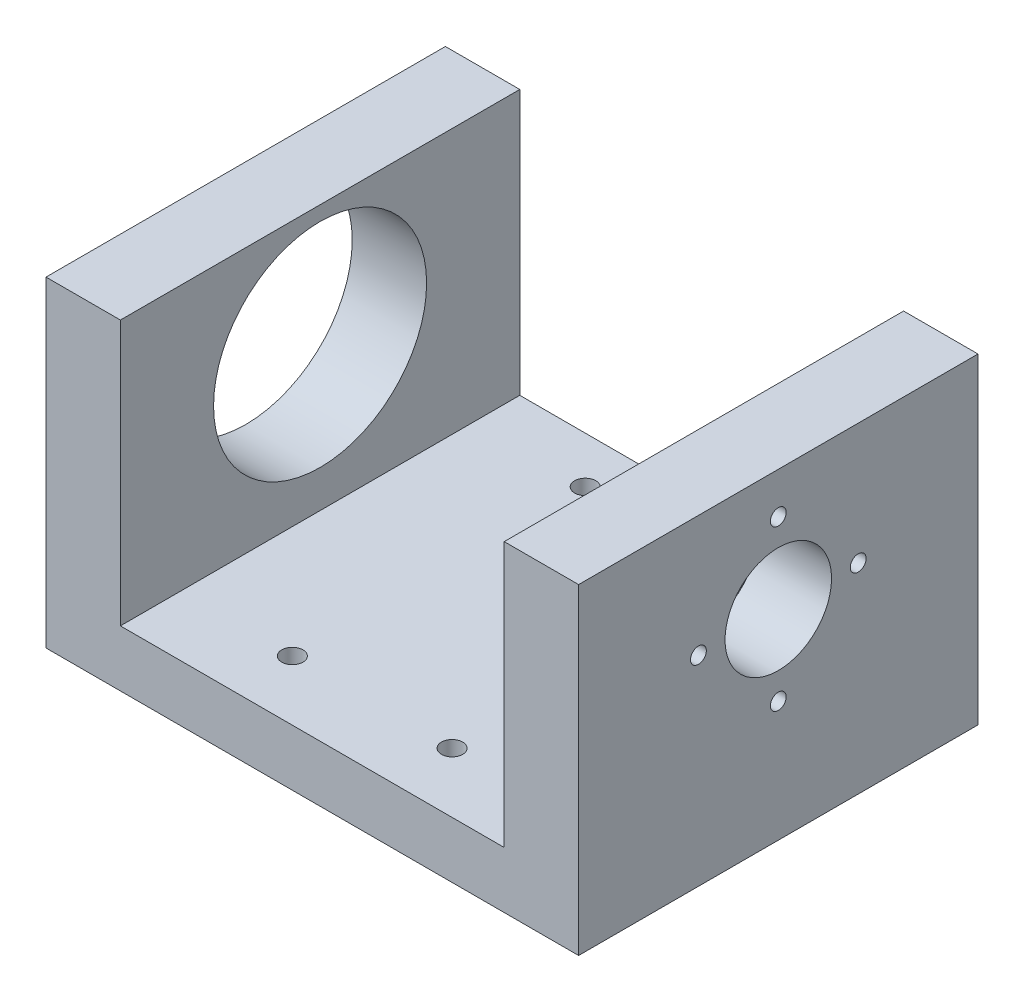
from build123d import *

# Parameters (mm, degrees)
SKETCH1_W                 = 40.0059906
SKETCH1_H                 = 24.13
BOSS_EXTRUDE1_DEPTH       = 30
SKETCH6_W                 = 28.8299906
SKETCH6_H                 = 19.896666666
CUT_EXTRUDE1_DEPTH        = 30
SKETCH9_R                 = 0.8
CUT_EXTRUDE3_DEPTH        = 30
SKETCH29_R                = 8.001
CUT_EXTRUDE4_DEPTH        = 5.588
SKETCH41_R                = 4
CUT_EXTRUDE5_DEPTH        = 5.588
F_0_80_TAPPED_HOLE1_D     = 1.19126
F_0_80_TAPPED_HOLE1_DEPTH = 5.588


with BuildPart() as part:
    # Sketch1 → Boss-Extrude1 (new body)
    with BuildSketch(Plane.XY):
        with Locations((3.348789693, 2.822850467)):
            Rectangle(SKETCH1_W, SKETCH1_H)
    extrude(amount=BOSS_EXTRUDE1_DEPTH)

    # Sketch6 → Cut-Extrude1 (cut)
    with BuildSketch(Plane.XY.offset(30)):
        with Locations((3.348789693, 4.939517134)):
            Rectangle(SKETCH6_W, SKETCH6_H)
    extrude(amount=-CUT_EXTRUDE1_DEPTH, mode=Mode.SUBTRACT)

    # Sketch9 → Cut-Extrude3 (cut)
    with BuildSketch(Plane(origin=(0, -9.242149533, 0), x_dir=(-1, 0, 0), z_dir=(0, -1, 0))):
        with Locations((2.651210307, -25.5)):
            Circle(SKETCH9_R)
        with Locations((-9.348789693, -25.5)):
            Circle(SKETCH9_R)
        with Locations((-9.348789693, -3.5)):
            Circle(SKETCH9_R)
        with Locations((2.651210307, -3.5)):
            Circle(SKETCH9_R)
    extrude(amount=-CUT_EXTRUDE3_DEPTH, mode=Mode.SUBTRACT)

    # Sketch29 → Cut-Extrude4 (cut)
    with BuildSketch(Plane.ZY.offset(16.654205607)):
        with Locations((15, 5.794650467)):
            Circle(SKETCH29_R)
    extrude(amount=-CUT_EXTRUDE4_DEPTH, mode=Mode.SUBTRACT)

    # Sketch41 → Cut-Extrude5 (cut)
    with BuildSketch(Plane(origin=(23.351784993, 0, 0), x_dir=(0, 0, -1), z_dir=(1, 0, 0))):
        with Locations((-15, 5.794650467)):
            Circle(SKETCH41_R)
    extrude(amount=-CUT_EXTRUDE5_DEPTH, mode=Mode.SUBTRACT)

    # #0-80 Tapped Hole1
    with Locations(Plane(origin=(23.351784993, 0, 0), x_dir=(0, 0, -1), z_dir=(1, 0, 0))):
        with Locations((-15, 11.794650467), (-9, 5.794650467), (-15, -0.205349533), (-21, 5.794650467)):
            Hole(F_0_80_TAPPED_HOLE1_D / 2, depth=F_0_80_TAPPED_HOLE1_DEPTH)


solid = part.part
